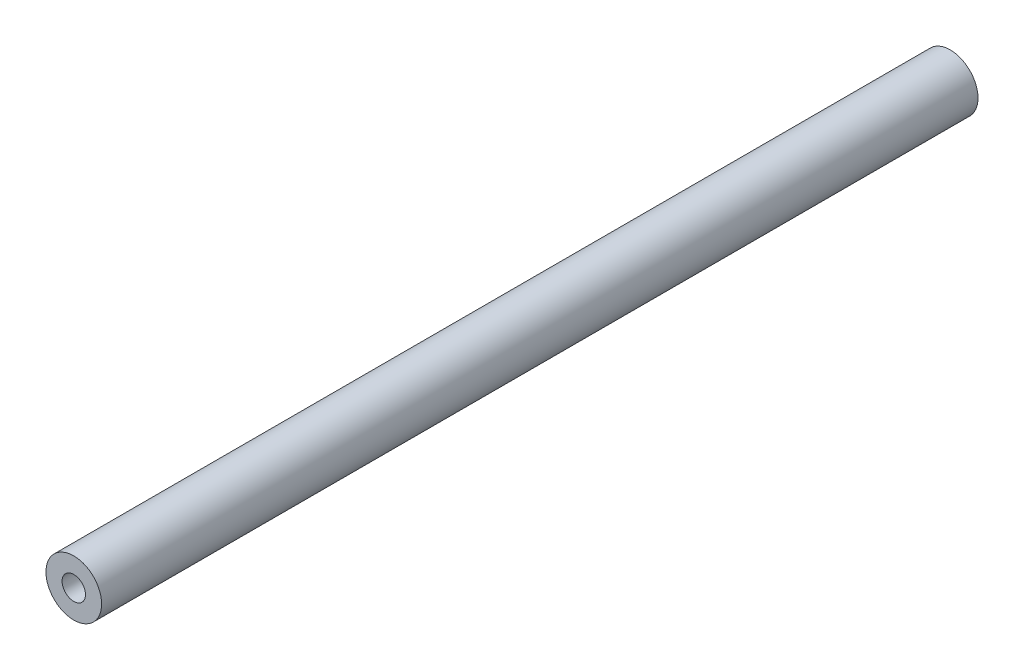
from build123d import *

# Parameters (mm, degrees)
CROQUIS1_R              = 4.7625
CROQUIS1_R_2            = 2
SALIENTE_EXTRUIR1_DEPTH = 150


with BuildPart() as part:
    # Croquis1 → Saliente-Extruir1 (new body)
    with BuildSketch(Plane.XY):
        Circle(CROQUIS1_R)
        Circle(CROQUIS1_R_2, mode=Mode.SUBTRACT)
    extrude(amount=SALIENTE_EXTRUIR1_DEPTH)


solid = part.part
